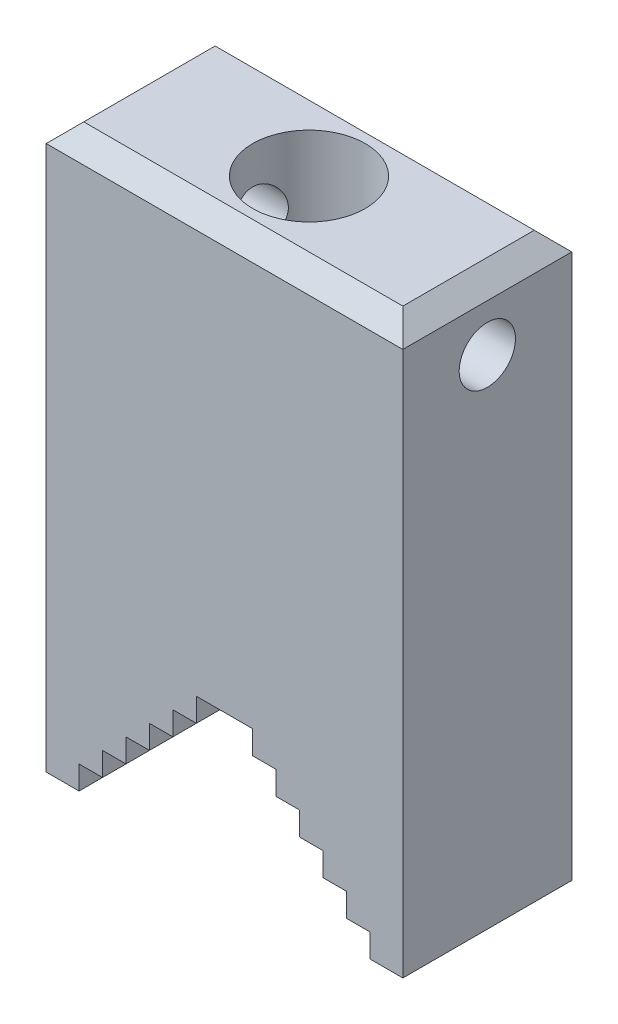
from build123d import *

# Parameters (mm, degrees)
SKETCH1_W               = 38
SKETCH1_H               = 60
BOSS_EXTRUDE1_DEPTH     = 9
CUT_EXTRUDE1_DEPTH      = 1
CUT_EXTRUDE1_DEPTH_BACK = 18
SKETCH5_R               = 3
CUT_EXTRUDE2_DEPTH      = 38
CHAMFER1_SIZE           = 2


with BuildPart() as part:
    # Sketch1 → Boss-Extrude1 (new body, symmetric)
    with BuildSketch(Plane.XY):
        with Locations((0, 30)):
            Rectangle(SKETCH1_W, SKETCH1_H)
    extrude(amount=BOSS_EXTRUDE1_DEPTH, both=True)

    # Sketch2 → Cut-Extrude1 (cut, two sides)
    with BuildSketch(Plane.XY.offset(9)) as cut_extrude1_sk:
        Polygon((-15.5, 2.5), (-15.5, 0), (15.5, 0), (15.5, 2.5), (13, 2.5), (13, 5), (10.5, 5), (10.5, 7.5), (8, 7.5), (8, 10), (5.5, 10), (5.5, 12.5), (3, 12.5), (3, 15), (-3, 15), (-3, 12.5), (-5.5, 12.5), (-5.5, 10), (-8, 10), (-8, 7.5), (-10.5, 7.5), (-10.5, 5), (-13, 5), (-13, 2.5), align=None)
    extrude(amount=CUT_EXTRUDE1_DEPTH, mode=Mode.SUBTRACT)
    extrude(cut_extrude1_sk.sketch, amount=-CUT_EXTRUDE1_DEPTH_BACK, mode=Mode.SUBTRACT)

    # Sketch4 → Cut-Revolve1 (revolve, cut)
    with BuildSketch(Plane.XY):
        Polygon((-6, 60), (-6, 40), (0, 36.535898385), (0, 60), align=None)
    revolve(axis=Axis((0, 73.07179677, 0), (0, -1, 0)), mode=Mode.SUBTRACT)

    # Sketch5 → Cut-Extrude2 (cut)
    with BuildSketch(Plane(origin=(19, 0, 0), x_dir=(0, 0, -1), z_dir=(1, 0, 0))):
        with Locations((0, 53)):
            Circle(SKETCH5_R)
    extrude(amount=-CUT_EXTRUDE2_DEPTH, mode=Mode.SUBTRACT)

    # Chamfer1
    chamfer1_edges = [part.edges().sort_by_distance(p)[0] for p in [
        (0, 60, 9),
        (0, 60, -9),
        (-19, 60, 0),
        (19, 60, 0),
    ]]
    chamfer(chamfer1_edges, length=CHAMFER1_SIZE)


solid = part.part
